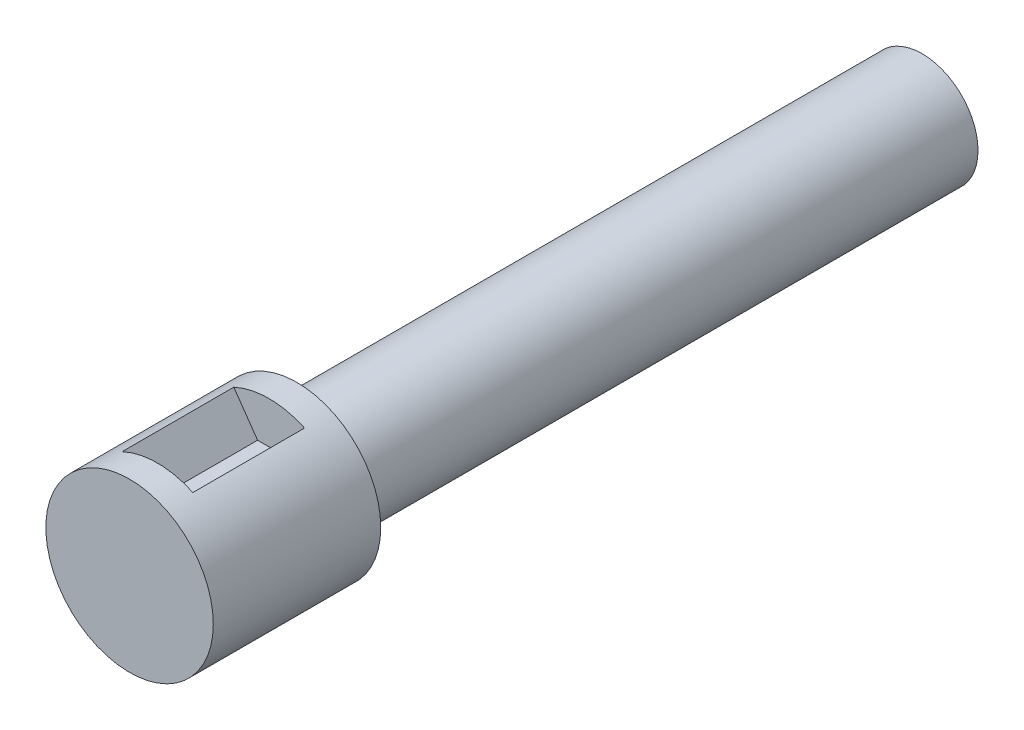
from build123d import *

# Parameters (mm, degrees)
SKETCH1_R           = 9.525
BOSS_EXTRUDE1_DEPTH = 19.05
SKETCH2_R           = 6.35
BOSS_EXTRUDE2_DEPTH = 71.12
CUT_EXTRUDE1_DEPTH  = 9.144
CUT_EXTRUDE2_START  = -3.175
CUT_EXTRUDE2_DEPTH  = 12.7


with BuildPart() as part:
    # Sketch1 → Boss-Extrude1 (new body)
    with BuildSketch(Plane.XY):
        Circle(SKETCH1_R)
    extrude(amount=BOSS_EXTRUDE1_DEPTH)

    # Sketch2 → Boss-Extrude2 (add)
    with BuildSketch(Plane(origin=(0, 0, 0), x_dir=(-1, 0, 0), z_dir=(0, 0, -1))):
        with Locations(Location((0, 0, 0), (0, 0, 180))):  # turned: the seam where the file's is
            Circle(SKETCH2_R)
    extrude(amount=BOSS_EXTRUDE2_DEPTH)

    # Sketch3 → Cut-Extrude1 (cut)
    with BuildSketch(Plane(origin=(0, 0, -71.12), x_dir=(-1, 0, 0), z_dir=(0, 0, -1))):
        with BuildLine():
            Line((-1.277821972, 1.524), (1.277821972, 1.524))
            ThreePointArc((1.277821972, 1.524), (1.98882, 0), (1.277821972, -1.524))
            Line((1.277821972, -1.524), (-1.277821972, -1.524))
            ThreePointArc((-1.277821972, -1.524), (-1.98882, 0), (-1.277821972, 1.524))
        make_face()
    extrude(amount=-CUT_EXTRUDE1_DEPTH, mode=Mode.SUBTRACT)

    # Sketch4 → Cut-Extrude2 (cut)
    with BuildSketch(Plane.XY.offset(19.05).offset(CUT_EXTRUDE2_START)):
        with BuildLine():
            Line((0, 4.7625), (-1.308111225, 4.7625))
            Line((-1.308111225, 4.7625), (-4.019808446, 8.635204981))
            ThreePointArc((-4.019808446, 8.635204981), (0.004701224, 9.52499884), (4.028330588, 8.631232686))
            Line((4.028330588, 8.631232686), (1.319414798, 4.7625))
            Line((1.319414798, 4.7625), (0, 4.7625))
        make_face()
    extrude(amount=-CUT_EXTRUDE2_DEPTH, mode=Mode.SUBTRACT)


solid = part.part
